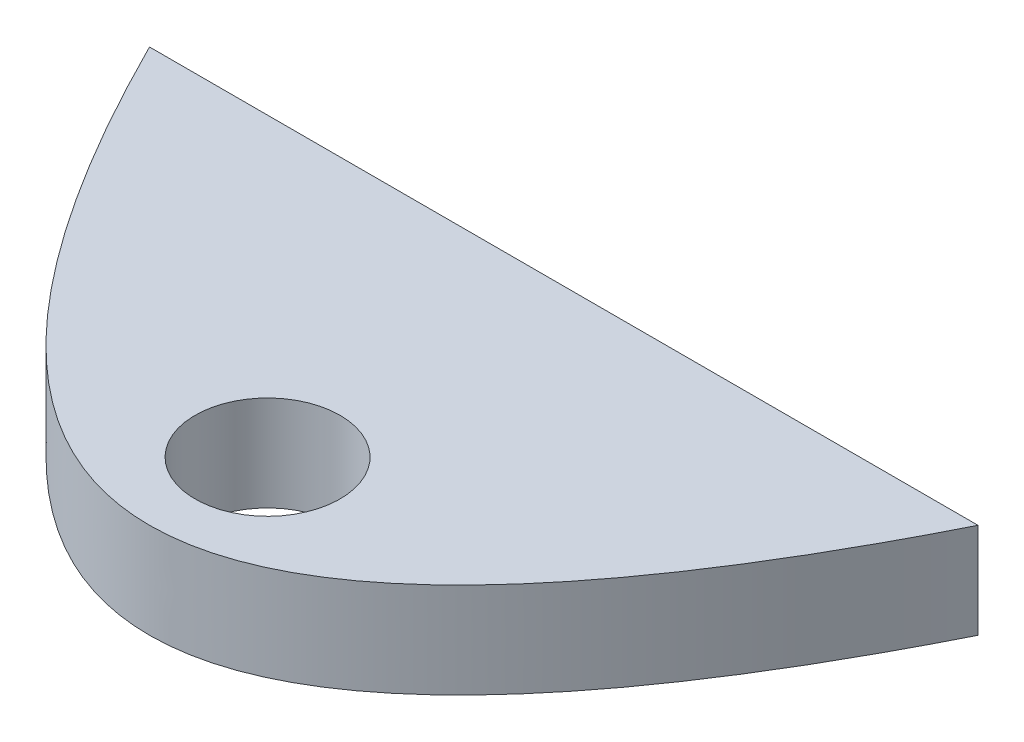
from build123d import *

# Parameters (mm, degrees)
BOSS_EXTRUDE1_DEPTH     = 300
SKETCH3_R               = 15.5
CUT_EXTRUDE1_DEPTH      = 23
CUT_EXTRUDE1_DEPTH_BACK = 23
SKETCH4_R               = 35
CUT_EXTRUDE3_DEPTH      = 300
SKETCH5_W               = 550.332786852
SKETCH5_H               = 261.274024582
CUT_EXTRUDE4_DEPTH      = 201.0000001


with BuildPart() as part:
    # Sketch1 → Boss-Extrude1 (new body)
    with BuildSketch(Plane(origin=(0, 0, 0), x_dir=(1, 0, 0), z_dir=(0, 1, 0))):
        with BuildLine():
            Line((-200, 1e-09), (200, 1e-09))
            add(Edge.make_bspline(
                [(-200, 1e-09), (0, -400.000000001), (200, 1e-09)],
                knots=[0.056028396, 0.056028396, 0.056028396, 0.943971604, 0.943971604, 0.943971604], degree=2))
        make_face()
    extrude(amount=BOSS_EXTRUDE1_DEPTH)

    # Sketch3 → Cut-Extrude1 (cut, two sides)
    with BuildSketch(Plane(origin=(0, 150, 0), x_dir=(1, 0, 0), z_dir=(0, 1, 0))) as cut_extrude1_sk:
        with Locations((0, -142.999999999)):
            Circle(SKETCH3_R)
    extrude(amount=CUT_EXTRUDE1_DEPTH, mode=Mode.SUBTRACT)
    extrude(cut_extrude1_sk.sketch, amount=-CUT_EXTRUDE1_DEPTH_BACK, mode=Mode.SUBTRACT)

    # Sketch4 → Cut-Extrude3 (cut)
    with BuildSketch(Plane(origin=(0, 173, 0), x_dir=(1, 0, 0), z_dir=(0, 1, 0))):
        with Locations((0, -142.999999999)):
            Circle(SKETCH4_R)
    cut_extrude3 = extrude(amount=CUT_EXTRUDE3_DEPTH, mode=Mode.SUBTRACT)

    # Mirror1: Cut-Extrude3 across plane
    add(cut_extrude3.mirror(Plane.ZX.offset(150)), mode=Mode.SUBTRACT)

    # Sketch5 → Cut-Extrude4 (cut, through all)
    with BuildSketch(Plane(origin=(0, 0, 0), x_dir=(-1, 0, 0), z_dir=(0, 0, -1))):
        with Locations((-5.361966922, 176.637012291)):
            Rectangle(SKETCH5_W, SKETCH5_H)
    extrude(amount=-CUT_EXTRUDE4_DEPTH, mode=Mode.SUBTRACT)


solid = part.part
